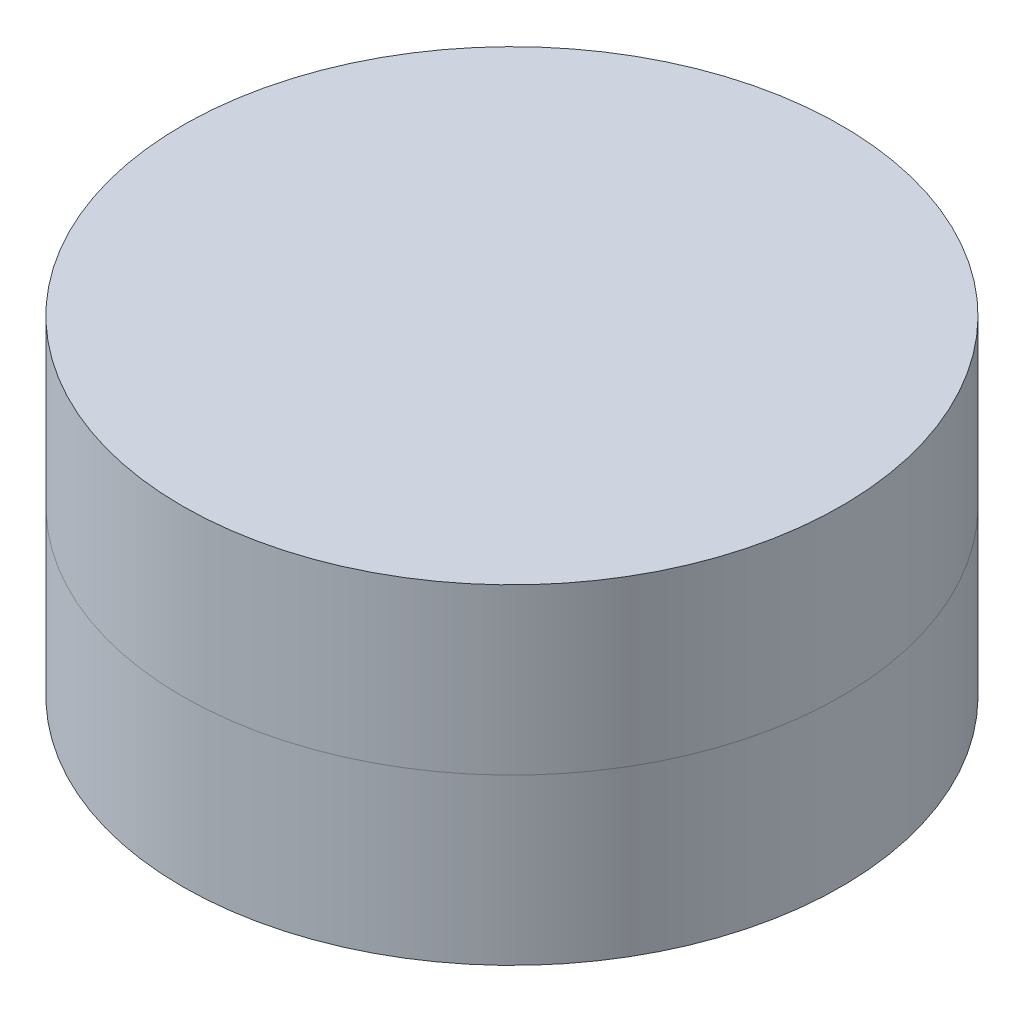
from build123d import *

# Parameters (mm, degrees)
SKETCH1_R           = 4.7625
BOSS_EXTRUDE1_DEPTH = 2.38125


with BuildPart() as part:
    # Sketch1 → Boss-Extrude1 (new body, symmetric)
    with BuildSketch(Plane(origin=(0, 0, 0), x_dir=(1, 0, 0), z_dir=(0, 1, 0))):
        Circle(SKETCH1_R)
    extrude(amount=BOSS_EXTRUDE1_DEPTH, both=True)


solid = part.part
